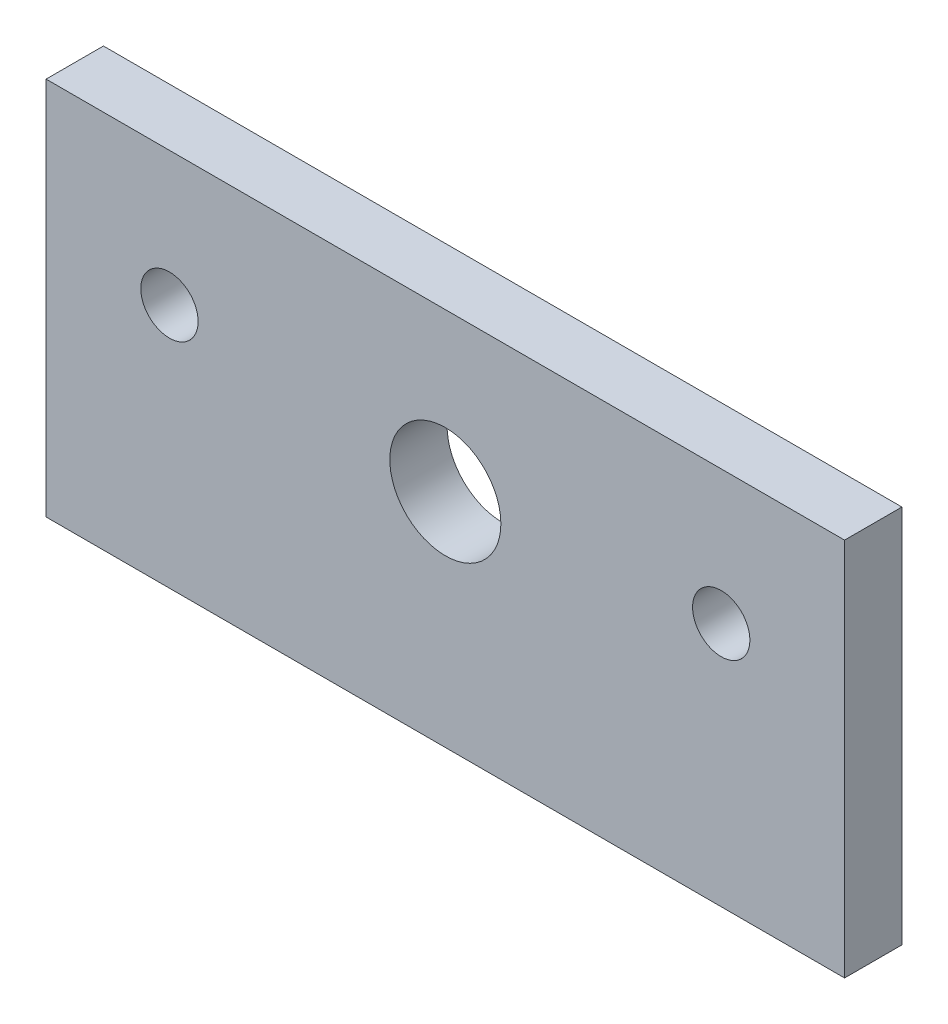
from build123d import *

# Parameters (mm, degrees)
SKETCH1_R           = 4
SKETCH1_R_2         = 5
BOSS_EXTRUDE1_DEPTH = 8
SKETCH2_R           = 7.75
CUT_EXTRUDE1_DEPTH  = 9


with BuildPart() as part:
    # Sketch1 → Boss-Extrude1 (new body)
    with BuildSketch(Plane.XY):
        Polygon((-55.929590299, 11.283196531), (55.49624814, 11.283196531), (55.49624814, -41.637870342), (-55.929590299, -41.637870342), (-55.929590299, -36.557898132), align=None)
        with Locations((38.28332892, -7.416803469)):
            Circle(SKETCH1_R, mode=Mode.SUBTRACT)
        with Locations((-0.21667108, -10.716803469)):
            Circle(SKETCH1_R_2, mode=Mode.SUBTRACT)
        with Locations((-38.71667108, -7.416803469)):
            Circle(SKETCH1_R, mode=Mode.SUBTRACT)
    extrude(amount=BOSS_EXTRUDE1_DEPTH)

    # Sketch2 → Cut-Extrude1 (cut, through all)
    with BuildSketch(Plane.XY.offset(8)):
        with Locations((-0.21667108, -10.716803469)):
            Circle(SKETCH2_R)
    extrude(amount=-CUT_EXTRUDE1_DEPTH, mode=Mode.SUBTRACT)


solid = part.part
